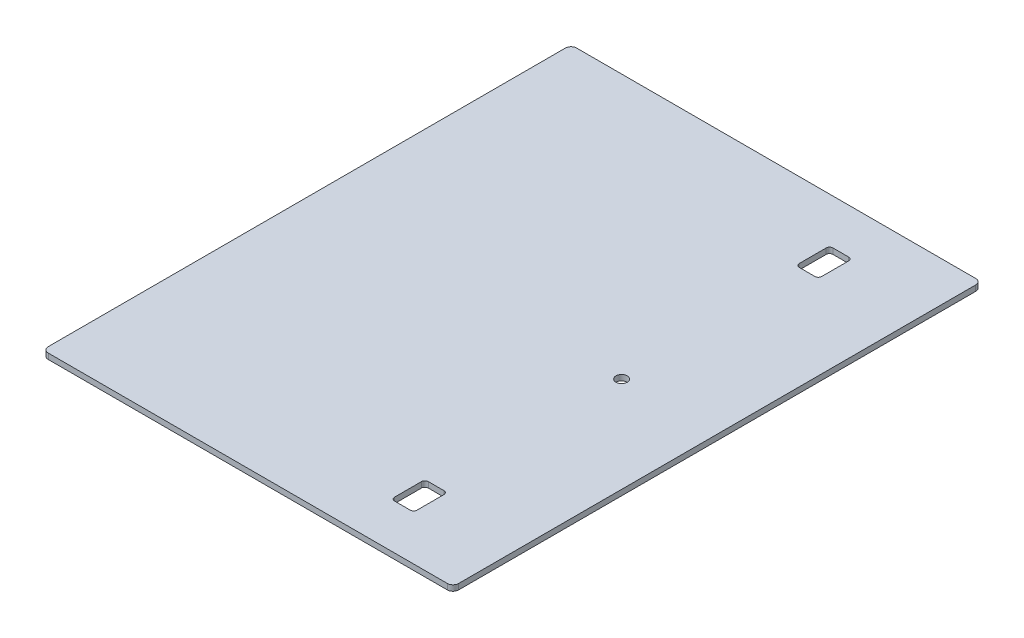
from build123d import *

# Parameters (mm, degrees)
SKETCH1_W                   = 231.775
SKETCH1_H                   = 298.45
BOSS_EXTRUDE1_DEPTH         = 3.175
F_1_4_0_25_DIAMETER_HOLE1_D = 6.35
FILLET1_R                   = 3.175
SKETCH4_W                   = 12.7
SKETCH4_H                   = 19.05
CUT_EXTRUDE1_DEPTH          = 4.175
FILLET2_R                   = 1.905


with BuildPart() as part:
    # Sketch1 → Boss-Extrude1 (new body)
    with BuildSketch(Plane(origin=(0, 0, 0), x_dir=(1, 0, 0), z_dir=(0, 1, 0))):
        Rectangle(SKETCH1_W, SKETCH1_H)
    extrude(amount=BOSS_EXTRUDE1_DEPTH)

    # 1/4 (0.25) Diameter Hole1 (through all)
    with Locations(Plane(origin=(0, 3.175, 0), x_dir=(1, 0, 0), z_dir=(0, 1, 0))):
        with Locations((61.9125, 0)):
            Hole(F_1_4_0_25_DIAMETER_HOLE1_D / 2)

    # Fillet1
    fillet1_edges = [part.edges().sort_by_distance(p)[0] for p in [
        (115.8875, 1.5875, 149.225),
        (-115.8875, 1.5875, 149.225),
        (-115.8875, 1.5875, -149.225),
        (115.8875, 1.5875, -149.225),
    ]]
    fillet(fillet1_edges, radius=FILLET1_R)

    # Sketch4 → Cut-Extrude1 (cut, through all)
    with BuildSketch(Plane(origin=(0, 3.175, 0), x_dir=(1, 0, 0), z_dir=(0, 1, 0))):
        with Locations((61.9125, -114.3)):
            Rectangle(SKETCH4_W, SKETCH4_H)
        with Locations((61.9125, 114.3)):
            Rectangle(SKETCH4_W, SKETCH4_H)
    extrude(amount=-CUT_EXTRUDE1_DEPTH, mode=Mode.SUBTRACT)

    # Fillet2
    fillet2_edges = [part.edges().sort_by_distance(p)[0] for p in [
        (55.5625, 1.5875, 123.825),
        (55.5625, 1.5875, 104.775),
        (68.2625, 1.5875, 104.775),
        (68.2625, 1.5875, 123.825),
        (55.5625, 1.5875, -104.775),
        (55.5625, 1.5875, -123.825),
        (68.2625, 1.5875, -123.825),
        (68.2625, 1.5875, -104.775),
    ]]
    fillet(fillet2_edges, radius=FILLET2_R)


solid = part.part
